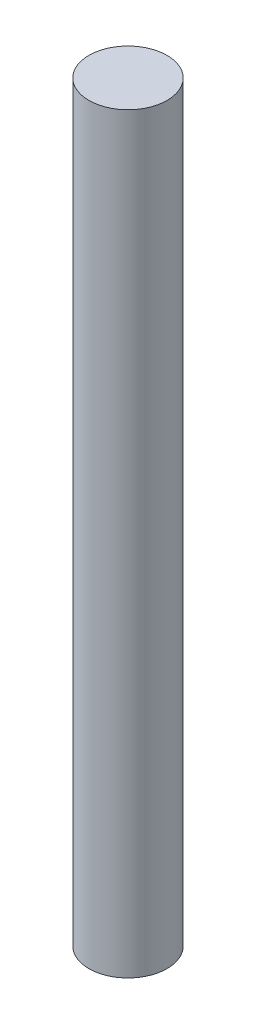
from build123d import *

# Parameters (mm, degrees)
CROQUIS1_R              = 4
SALIENTE_EXTRUIR1_DEPTH = 77


with BuildPart() as part:
    # Croquis1 → Saliente-Extruir1 (new body)
    with BuildSketch(Plane(origin=(0, 0, 0), x_dir=(1, 0, 0), z_dir=(0, 1, 0))):
        Circle(CROQUIS1_R)
    extrude(amount=SALIENTE_EXTRUIR1_DEPTH)


solid = part.part
